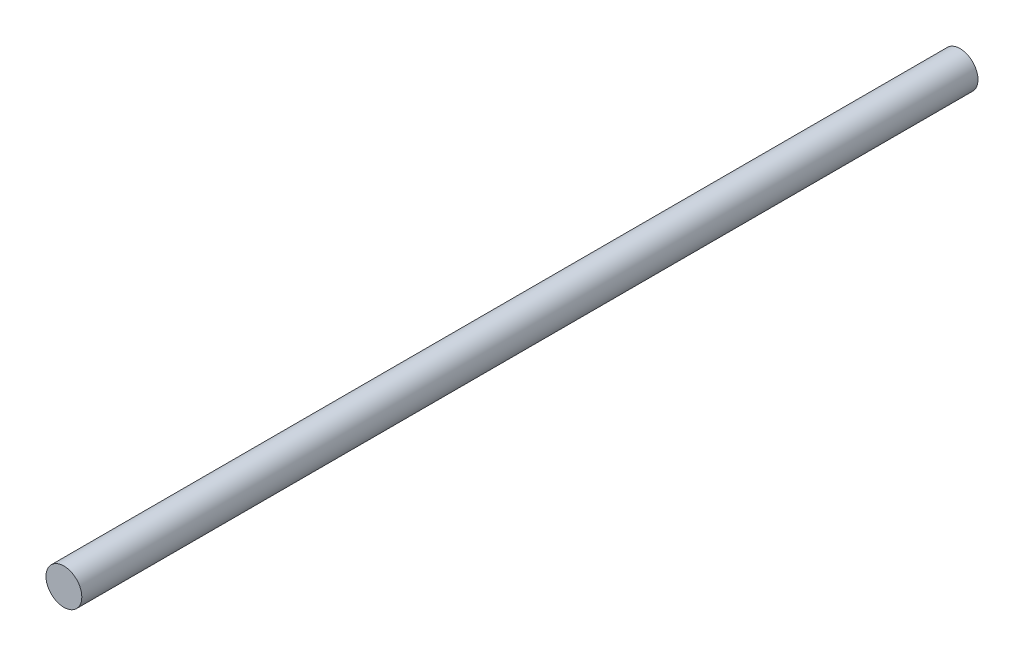
from build123d import *

# Parameters (mm, degrees)
CROQUIS1_R              = 5
SALIENTE_EXTRUIR1_DEPTH = 250


with BuildPart() as part:
    # Croquis1 → Saliente-Extruir1 (new body)
    with BuildSketch(Plane.XY):
        Circle(CROQUIS1_R)
    extrude(amount=SALIENTE_EXTRUIR1_DEPTH)


solid = part.part
